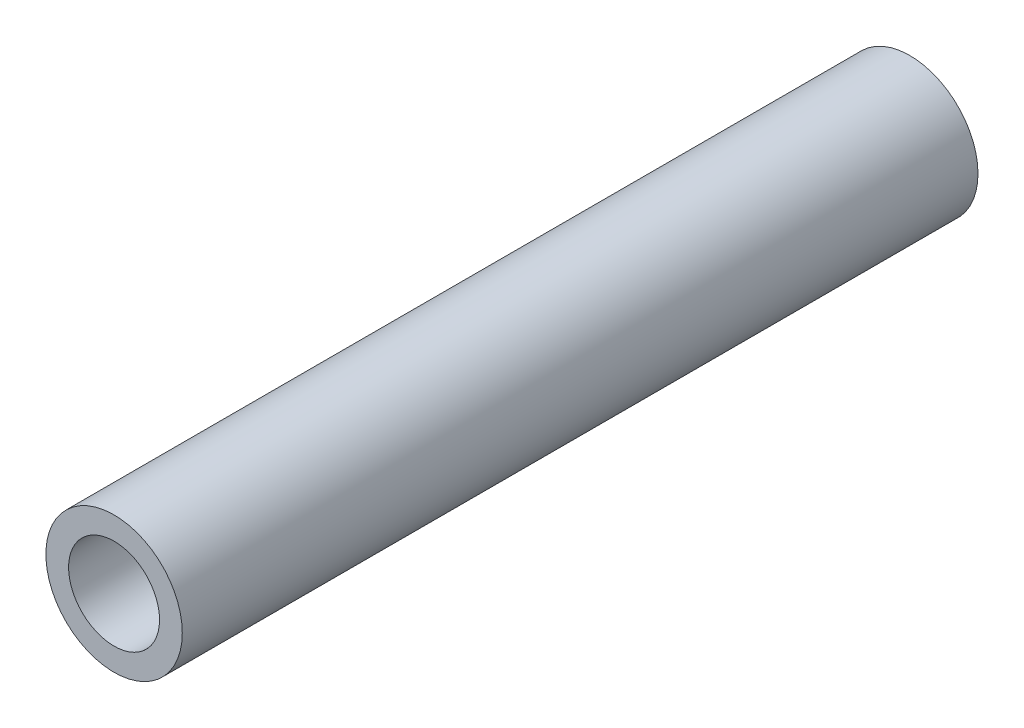
from build123d import *

# Parameters (mm, degrees)
SKETCH_1_R      = 3
SKETCH_1_R_2    = 2
EXTRUDE_1_DEPTH = 17.5


with BuildPart() as part:
    # 草图1 → 凸台-拉伸1 (new body, symmetric)
    with BuildSketch(Plane.XY):
        Circle(SKETCH_1_R)
        Circle(SKETCH_1_R_2, mode=Mode.SUBTRACT)
    extrude(amount=EXTRUDE_1_DEPTH, both=True)


solid = part.part
